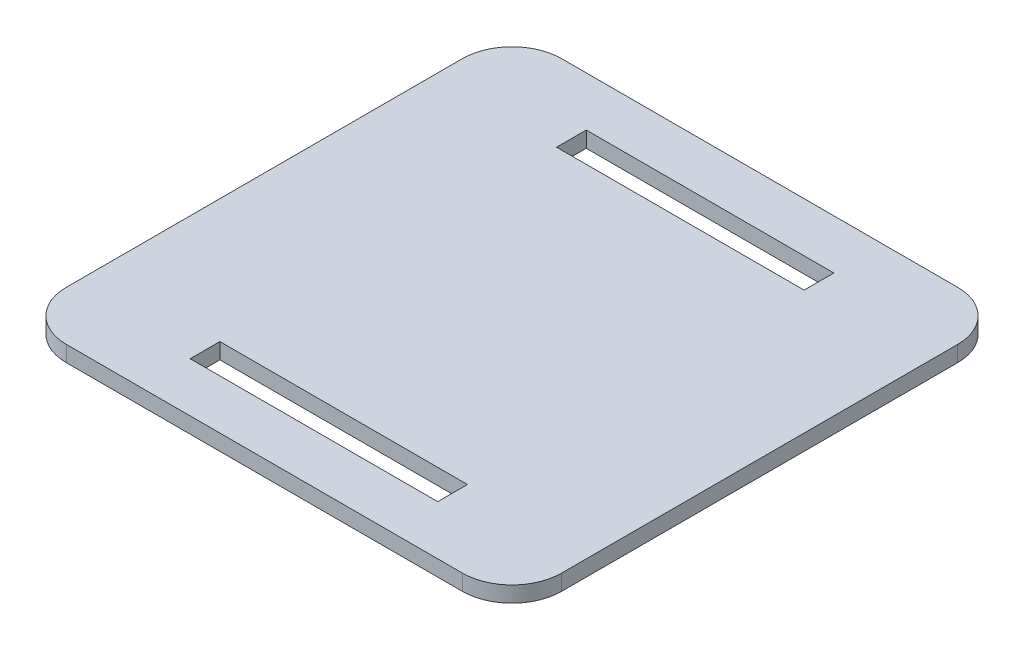
from build123d import *

# Parameters (mm, degrees)
SKETCH1_W           = 50
SKETCH1_H           = 50
BOSS_EXTRUDE1_DEPTH = 1.6
SKETCH2_W           = 25
SKETCH2_H           = 3
CUT_EXTRUDE1_DEPTH  = 1.6
FILLET1_R           = 5
FILLET2_R           = 5
FILLET3_R           = 5


with BuildPart() as part:
    # Sketch1 → Boss-Extrude1 (new body)
    with BuildSketch(Plane(origin=(0, 0, 0), x_dir=(1, 0, 0), z_dir=(0, 1, 0))):
        with Locations((25, 25)):
            Rectangle(SKETCH1_W, SKETCH1_H)
    extrude(amount=BOSS_EXTRUDE1_DEPTH)

    # Sketch2 → Cut-Extrude1 (cut)
    with BuildSketch(Plane.XZ):
        with Locations((25, -6.5)):
            Rectangle(SKETCH2_W, SKETCH2_H)
        with Locations((25, -43.5)):
            Rectangle(SKETCH2_W, SKETCH2_H)
    extrude(amount=-CUT_EXTRUDE1_DEPTH, mode=Mode.SUBTRACT)

    # Fillet1
    fillet1_edges = [part.edges().sort_by_distance(p)[0] for p in [
        (0, 0.8, 0),
        (50, 0.8, 0),
    ]]
    fillet(fillet1_edges, radius=FILLET1_R)

    # Fillet2
    fillet2_edges = [part.edges().sort_by_distance(p)[0] for p in [
        (50, 0.8, -50),
    ]]
    fillet(fillet2_edges, radius=FILLET2_R)

    # Fillet3
    fillet3_edges = [part.edges().sort_by_distance(p)[0] for p in [
        (0, 0.8, -50),
    ]]
    fillet(fillet3_edges, radius=FILLET3_R)


solid = part.part
